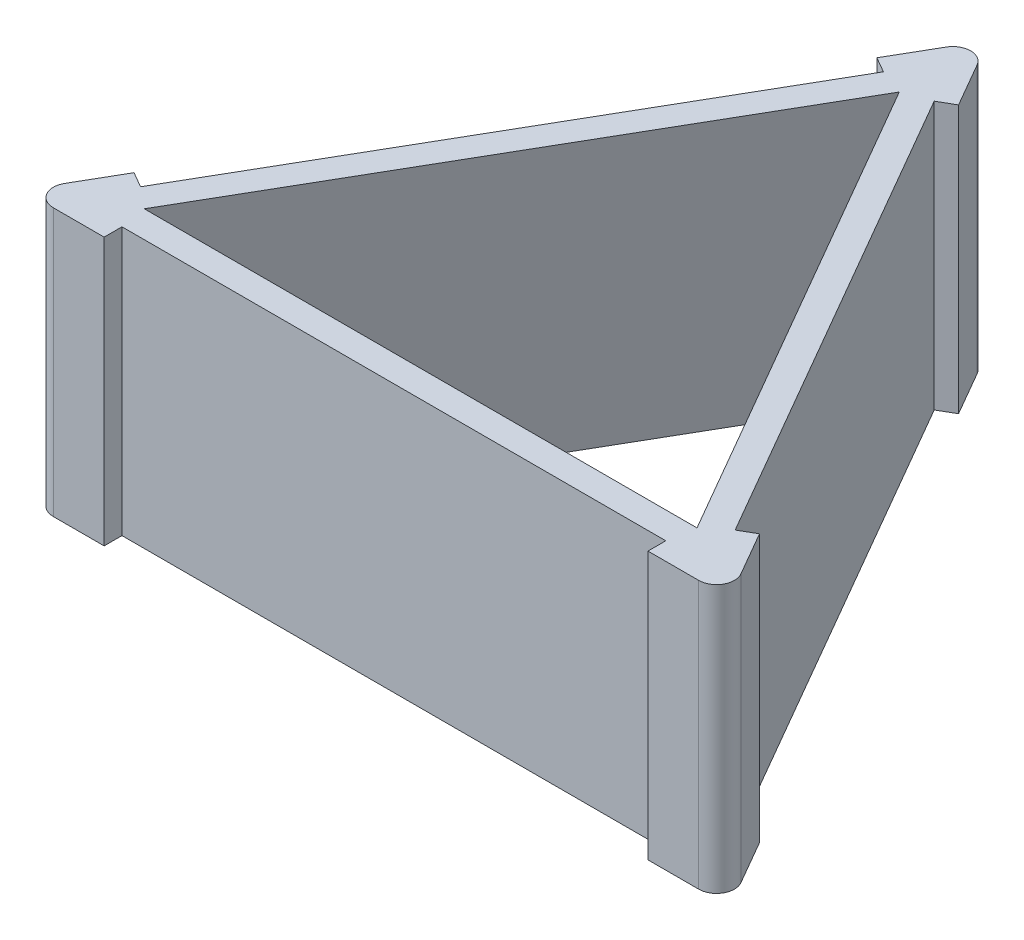
from build123d import *

# Parameters (mm, degrees)
BOSS_EXTRUDE1_DEPTH = 19.05
SKETCH3_W           = 77.47
SKETCH3_H           = 38.1
CUT_EXTRUDE1_DEPTH  = 2.54
CIRPATTERN1_COUNT   = 3
FILLET1_R           = 2.54


with BuildPart() as part:
    # Sketch1 → Boss-Extrude1 (new body, symmetric)
    with BuildSketch(Plane(origin=(0, 0, 0), x_dir=(1, 0, 0), z_dir=(0, 1, 0))):
        Polygon((0, 58.160560196), (-50.368522628, -29.080280098), (50.368522628, -29.080280098), align=None)
        Polygon((-39.37, -22.730280098), (39.37, -22.730280098), (0, 45.460560196), align=None, mode=Mode.SUBTRACT)
    extrude(amount=BOSS_EXTRUDE1_DEPTH, both=True)

    # Sketch3 → Cut-Extrude1 (cut)
    with BuildSketch(Plane.XY.offset(29.080280098)):
        Rectangle(SKETCH3_W, SKETCH3_H)
    cut_extrude1 = extrude(amount=-CUT_EXTRUDE1_DEPTH, mode=Mode.SUBTRACT)

    # CirPattern1: Cut-Extrude1 ×3 about axis
    cirpattern1_axis = Axis((0, 0, 0), (0, 1, 0))
    for i in range(1, CIRPATTERN1_COUNT):
        add(cut_extrude1.rotate(cirpattern1_axis, i * 360 / CIRPATTERN1_COUNT), mode=Mode.SUBTRACT)

    # Fillet1
    fillet1_edges = [part.edges().sort_by_distance(p)[0] for p in [
        (50.368522628, 0, 29.080280098),
        (-50.368522628, 0, 29.080280098),
        (0, 0, -58.160560196),
    ]]
    fillet(fillet1_edges, radius=FILLET1_R)


solid = part.part
